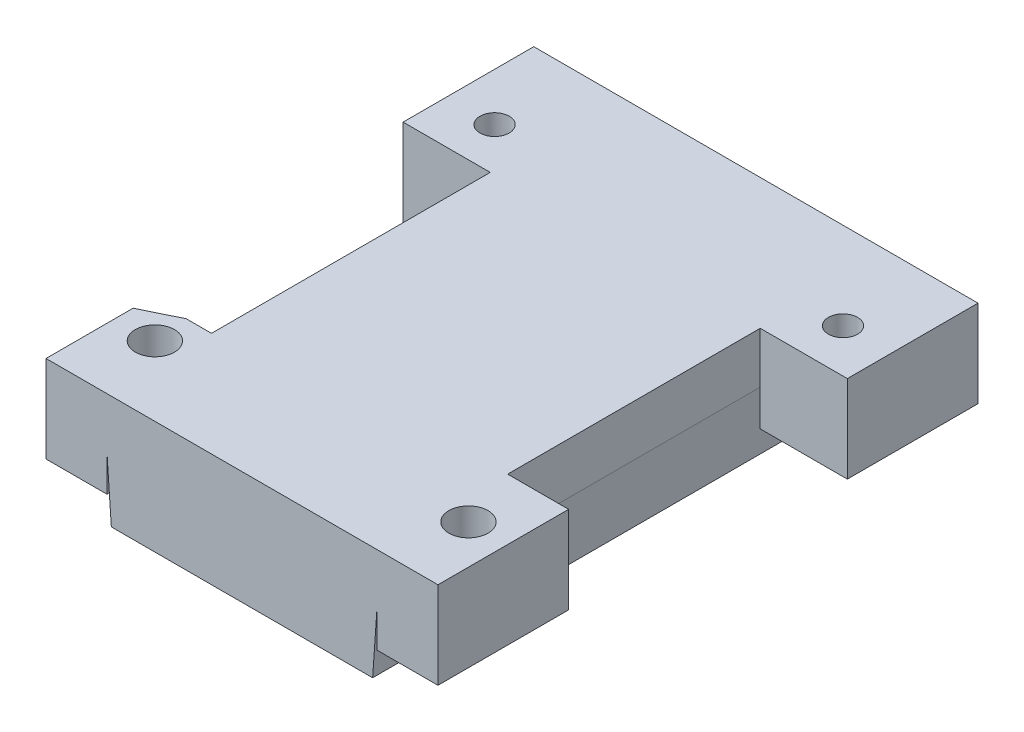
from build123d import *

# Parameters (mm, degrees)
SKETCH1_W           = 26
SKETCH1_H           = 53
SKETCH1_W_2         = 20
SKETCH1_H_2         = 10
BOSS_EXTRUDE1_DEPTH = 5
SKETCH2_W           = 31
SKETCH2_H           = 59
SKETCH2_W_2         = 26
SKETCH2_H_2         = 53
BOSS_EXTRUDE2_DEPTH = 10
SKETCH3_W           = 31
SKETCH3_H           = 59
BOSS_EXTRUDE3_DEPTH = 3
CHAMFER1_SIZE       = 0.5
CHAMFER1_SIZE2      = 7.150333128
SKETCH10_W          = 7
SKETCH10_H          = 15
SKETCH10_R          = 2.25
BOSS_EXTRUDE7_DEPTH = 10
SKETCH11_W          = 7
SKETCH11_H          = 3
CUT_EXTRUDE4_DEPTH  = 10
CHAMFER2_SIZE       = 2
CHAMFER2_SIZE2      = 4.100607683
SKETCH12_W          = 10
SKETCH12_H          = 15
SKETCH12_R          = 1.676379865
BOSS_EXTRUDE8_DEPTH = 10


with BuildPart() as part:
    # Sketch1 → Boss-Extrude1 (new body)
    with BuildSketch(Plane(origin=(0, 0, 0), x_dir=(1, 0, 0), z_dir=(0, 1, 0))):
        with Locations((-13, 26.5)):
            Rectangle(SKETCH1_W, SKETCH1_H)
        with Locations((-13, 27)):
            Rectangle(SKETCH1_W_2, SKETCH1_H_2, mode=Mode.SUBTRACT)
        with Locations((-13, 43)):
            Rectangle(SKETCH1_W_2, SKETCH1_H_2, mode=Mode.SUBTRACT)
        with Locations((-13, 11)):
            Rectangle(SKETCH1_W_2, SKETCH1_H_2, mode=Mode.SUBTRACT)
    extrude(amount=BOSS_EXTRUDE1_DEPTH)

    # Sketch2 → Boss-Extrude2 (add)
    with BuildSketch(Plane(origin=(0, 5, 0), x_dir=(1, 0, 0), z_dir=(0, 1, 0))):
        with Locations((-13, 26.5)):
            Rectangle(SKETCH2_W, SKETCH2_H)
        with Locations((-13, 26.5)):
            Rectangle(SKETCH2_W_2, SKETCH2_H_2, mode=Mode.SUBTRACT)
    extrude(amount=-BOSS_EXTRUDE2_DEPTH)

    # Sketch3 → Boss-Extrude3 (add)
    with BuildSketch(Plane(origin=(0, 5, 0), x_dir=(1, 0, 0), z_dir=(0, 1, 0))):
        with Locations((-13, 26.5)):
            Rectangle(SKETCH3_W, SKETCH3_H)
    extrude(amount=BOSS_EXTRUDE3_DEPTH)

    # Chamfer1
    chamfer1_edges = [part.edges().sort_by_distance(p)[0] for p in [
        (-28.5, -5, -26.5),
        (2.5, -5, -26.5),
    ]]
    chamfer1_side = [part.faces().sort_by_distance(p)[0] for p in [
        (-13, -5, -55.333516692),
    ]]
    chamfer(chamfer1_edges, length=CHAMFER1_SIZE, length2=CHAMFER1_SIZE2, reference=chamfer1_side[0])

    # Sketch10 → Boss-Extrude7 (add)
    with BuildSketch(Plane(origin=(0, 8, 0), x_dir=(1, 0, 0), z_dir=(0, 1, 0))):
        with Locations((6, 4.5)):
            Rectangle(SKETCH10_W, SKETCH10_H)
        with Locations((5, 5)):
            Circle(SKETCH10_R, mode=Mode.SUBTRACT)
        with Locations((-32, 4.5)):
            Rectangle(SKETCH10_W, SKETCH10_H)
        with Locations((-31, 5)):
            Circle(SKETCH10_R, mode=Mode.SUBTRACT)
    extrude(amount=-BOSS_EXTRUDE7_DEPTH)

    # Sketch11 → Cut-Extrude4 (cut)
    with BuildSketch(Plane(origin=(0, 8, 0), x_dir=(1, 0, 0), z_dir=(0, 1, 0))):
        with Locations((-32, 10.5)):
            Rectangle(SKETCH11_W, SKETCH11_H)
    extrude(amount=-CUT_EXTRUDE4_DEPTH, mode=Mode.SUBTRACT)

    # Chamfer2
    chamfer2_edges = [part.edges().sort_by_distance(p)[0] for p in [
        (-35.5, 3, -9),
    ]]
    chamfer2_side = [part.faces().sort_by_distance(p)[0] for p in [
        (-35.5, 3, -3),
    ]]
    chamfer(chamfer2_edges, length=CHAMFER2_SIZE, length2=CHAMFER2_SIZE2, reference=chamfer2_side[0])

    # Sketch12 → Boss-Extrude8 (add)
    with BuildSketch(Plane(origin=(0, 8, 0), x_dir=(1, 0, 0), z_dir=(0, 1, 0))):
        with Locations((7.5, 48.5)):
            Rectangle(SKETCH12_W, SKETCH12_H)
        with Locations((7, 46)):
            Circle(SKETCH12_R, mode=Mode.SUBTRACT)
        with Locations((-33.5, 48.5)):
            Rectangle(SKETCH12_W, SKETCH12_H)
        with Locations((-33, 46)):
            Circle(SKETCH12_R, mode=Mode.SUBTRACT)
    extrude(amount=-BOSS_EXTRUDE8_DEPTH)


solid = part.part
